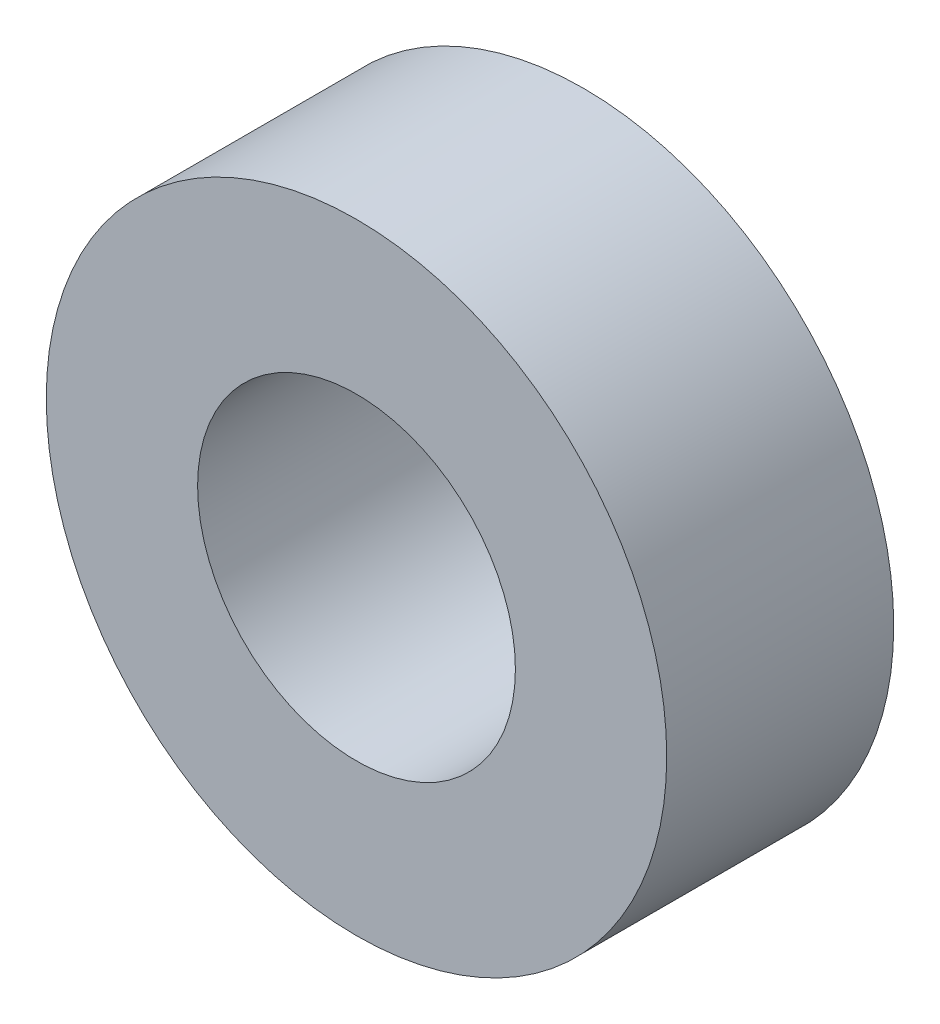
from build123d import *

# Parameters (mm, degrees)
ESQUISSE1_R        = 2.05
ESQUISSE1_R_2      = 1.05
EXTRU_MINCE1_DEPTH = 1.5


with BuildPart() as part:
    # Esquisse1 → Extru.-Mince1 (new body)
    with BuildSketch(Plane.XY):
        Circle(ESQUISSE1_R)
        Circle(ESQUISSE1_R_2, mode=Mode.SUBTRACT)
    extrude(amount=EXTRU_MINCE1_DEPTH)


solid = part.part
